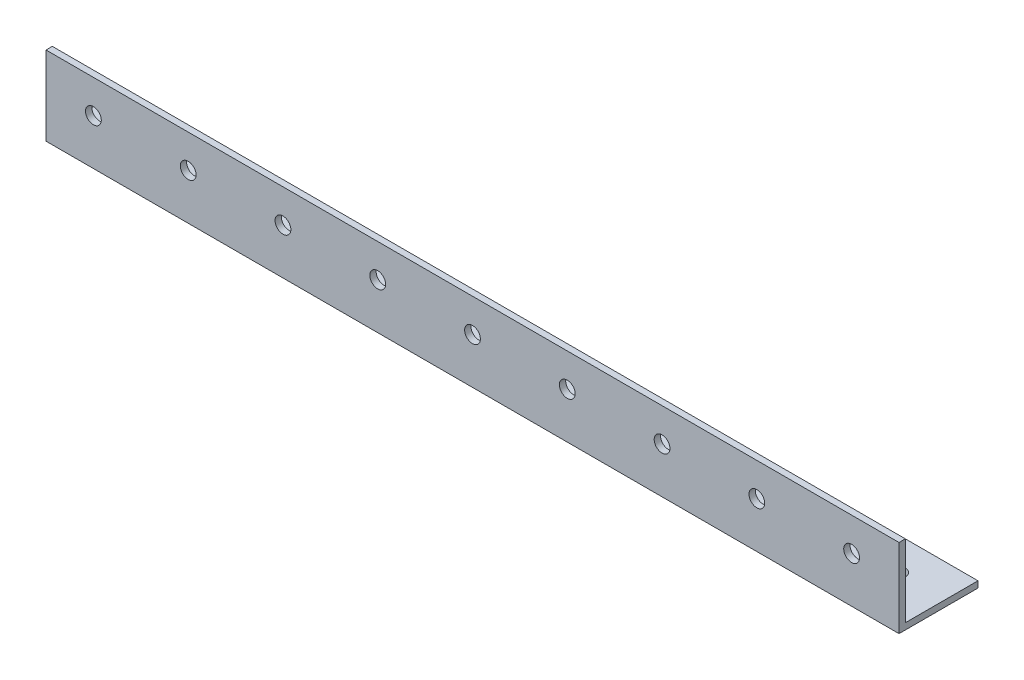
from build123d import *

# Parameters (mm, degrees)
EXTRUDE_1_DEPTH     = 540
SKETCH_2_R          = 5
CUT_EXTRUDE_1_DEPTH = 51
SKETCH_3_R          = 5
CUT_EXTRUDE_2_DEPTH = 51


with BuildPart() as part:
    # Эскиз1 → Вытянуть-Тонкостенный1 (new body)
    with BuildSketch(Plane(origin=(0, 0, 0), x_dir=(0, 0, -1), z_dir=(1, 0, 0))):
        Polygon((50, 0), (0, 0), (0, 50), (4, 50), (4, 4), (50, 4), align=None)
    extrude(amount=EXTRUDE_1_DEPTH)

    # Эскиз2 → Вырез-Вытянуть1 (cut, through all)
    with BuildSketch(Plane.XY):
        with Locations((30, 29)):
            Circle(SKETCH_2_R)
        with Locations((90, 29)):
            Circle(SKETCH_2_R)
        with Locations((150, 29)):
            Circle(SKETCH_2_R)
        with Locations((210, 29)):
            Circle(SKETCH_2_R)
        with Locations((270, 29)):
            Circle(SKETCH_2_R)
        with Locations((330, 29)):
            Circle(SKETCH_2_R)
        with Locations((390, 29)):
            Circle(SKETCH_2_R)
        with Locations((450, 29)):
            Circle(SKETCH_2_R)
        with Locations((510, 29)):
            Circle(SKETCH_2_R)
    extrude(amount=-CUT_EXTRUDE_1_DEPTH, mode=Mode.SUBTRACT)

    # Эскиз3 → Вырез-Вытянуть2 (cut, through all)
    with BuildSketch(Plane.XZ):
        with Locations((30, -29)):
            Circle(SKETCH_3_R)
        with Locations((90, -29)):
            Circle(SKETCH_3_R)
        with Locations((150, -29)):
            Circle(SKETCH_3_R)
        with Locations((210, -29)):
            Circle(SKETCH_3_R)
        with Locations((270, -29)):
            Circle(SKETCH_3_R)
        with Locations((330, -29)):
            Circle(SKETCH_3_R)
        with Locations((390, -29)):
            Circle(SKETCH_3_R)
        with Locations((450, -29)):
            Circle(SKETCH_3_R)
        with Locations((510, -29)):
            Circle(SKETCH_3_R)
    extrude(amount=-CUT_EXTRUDE_2_DEPTH, mode=Mode.SUBTRACT)


solid = part.part
